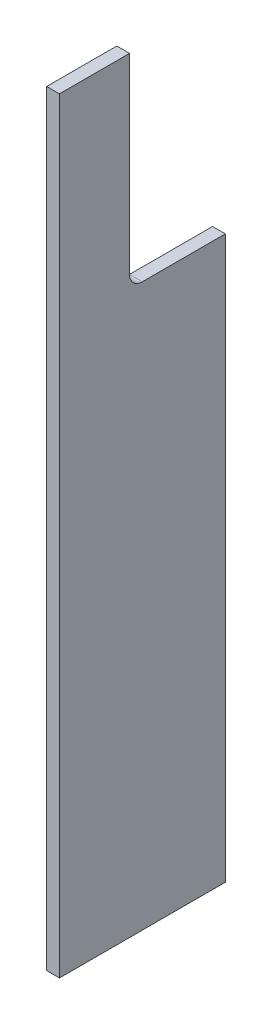
from build123d import *

# Parameters (mm, degrees)
ESQUISSE1_W             = 10
ESQUISSE1_H             = 600
BOSS_EXTRU_1_DEPTH      = 129.973967
ENL_V_MAT_EXTRU_1_DEPTH = 10


with BuildPart() as part:
    # Esquisse1 → Boss.-Extru.1 (new body)
    with BuildSketch(Plane.XY):
        with Locations((-160.641983179, 300)):
            Rectangle(ESQUISSE1_W, ESQUISSE1_H)
    extrude(amount=BOSS_EXTRU_1_DEPTH)

    # Esquisse2 → Enlèv. mat.-Extru.1 (cut)
    with BuildSketch(Plane(origin=(-155.641983179, 0, 0), x_dir=(0, 0, -1), z_dir=(1, 0, 0))):
        with BuildLine():
            Line((0, 600), (-75.04598428, 600))
            Line((-75.04598428, 600), (-75.04598428, 450))
            ThreePointArc((-75.04598428, 450), (-72.117052092, 442.928932188), (-65.04598428, 440))
            Line((-65.04598428, 440), (0, 440))
            Line((0, 440), (0, 600))
        make_face()
    extrude(amount=-ENL_V_MAT_EXTRU_1_DEPTH, mode=Mode.SUBTRACT)


solid = part.part
